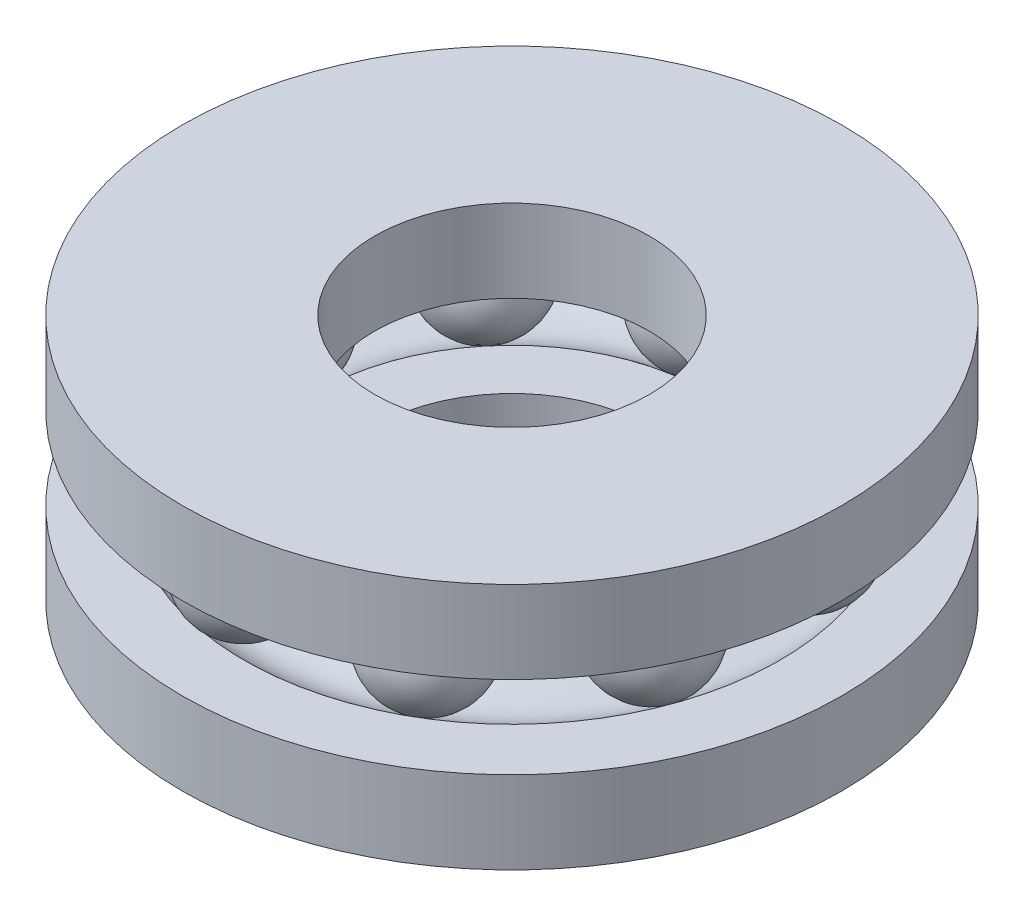
from build123d import *

# Parameters (mm, degrees)
MATRIZC2_COUNT = 9


with BuildPart() as part:
    # Croquis3 → Revolución5 (revolve)
    with BuildSketch(Plane.XY):
        with BuildLine():
            Line((-9.751201897, 3), (-12, 3))
            Line((-12, 3), (-12, 0))
            Line((-12, 0), (-5, 0))
            Line((-5, 0), (-5, 3))
            Line((-5, 3), (-7.146949089, 3))
            ThreePointArc((-7.146949089, 3), (-8.449075493, 2.518047044), (-9.751201897, 3))
        make_face()
        with BuildLine():
            Line((-12, 6), (-9.792137456, 6))
            ThreePointArc((-9.792137456, 6), (-8.449075493, 6.518047044), (-7.106013531, 6))
            Line((-7.106013531, 6), (-5, 6))
            Line((-5, 6), (-5, 9))
            Line((-5, 9), (-12, 9))
            Line((-12, 9), (-12, 6))
        make_face()
    revolve(axis=Axis((0, 0, 0), (0, 1, 0)))


with BuildPart() as body_2:
    # Croquis2 → Revolución4 (revolve)
    with BuildSketch(Plane.XY):
        with BuildLine():
            Line((-8.449075493, 6.518047044), (-8.449075493, 2.518047044))
            ThreePointArc((-8.449075493, 2.518047044), (-10.449075493, 4.518047044), (-8.449075493, 6.518047044))
        make_face()
    revolve(axis=Axis((-8.449075493, 6.518047044, 0), (0, -1, 0)))


with BuildPart() as matrizc2_1:
    # MatrizC2: pattern copy
    add(body_2.part.rotate(Axis((0, 0, 0), (0, 1, 0)), 1 * 360 / MATRIZC2_COUNT))


with BuildPart() as matrizc2_2:
    # MatrizC2: pattern copy
    add(body_2.part.rotate(Axis((0, 0, 0), (0, 1, 0)), 2 * 360 / MATRIZC2_COUNT))


with BuildPart() as matrizc2_3:
    # MatrizC2: pattern copy
    add(body_2.part.rotate(Axis((0, 0, 0), (0, 1, 0)), 3 * 360 / MATRIZC2_COUNT))


with BuildPart() as matrizc2_4:
    # MatrizC2: pattern copy
    add(body_2.part.rotate(Axis((0, 0, 0), (0, 1, 0)), 4 * 360 / MATRIZC2_COUNT))


with BuildPart() as matrizc2_5:
    # MatrizC2: pattern copy
    add(body_2.part.rotate(Axis((0, 0, 0), (0, 1, 0)), 5 * 360 / MATRIZC2_COUNT))


with BuildPart() as matrizc2_6:
    # MatrizC2: pattern copy
    add(body_2.part.rotate(Axis((0, 0, 0), (0, 1, 0)), 6 * 360 / MATRIZC2_COUNT))


with BuildPart() as matrizc2_7:
    # MatrizC2: pattern copy
    add(body_2.part.rotate(Axis((0, 0, 0), (0, 1, 0)), 7 * 360 / MATRIZC2_COUNT))


with BuildPart() as matrizc2_8:
    # MatrizC2: pattern copy
    add(body_2.part.rotate(Axis((0, 0, 0), (0, 1, 0)), 8 * 360 / MATRIZC2_COUNT))


solid = Compound([part.part, body_2.part, matrizc2_1.part, matrizc2_2.part, matrizc2_3.part, matrizc2_4.part, matrizc2_5.part, matrizc2_6.part, matrizc2_7.part, matrizc2_8.part])
